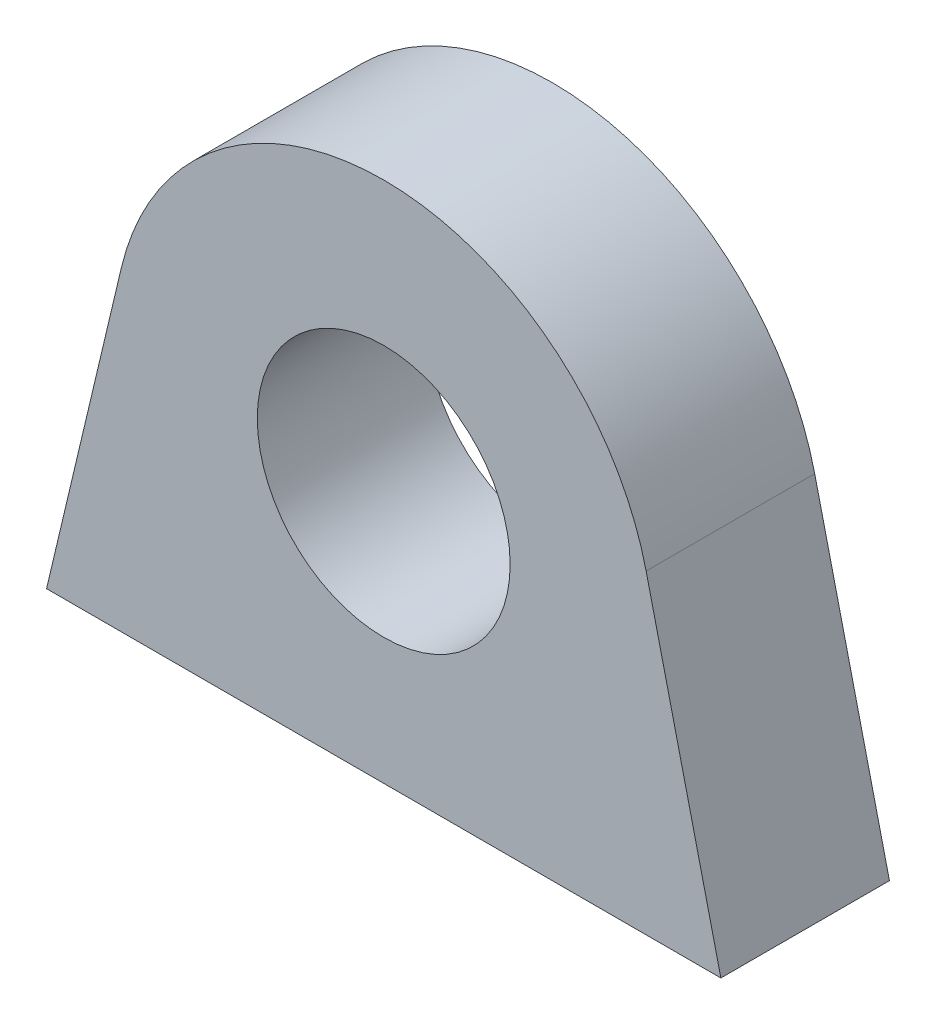
from build123d import *

# Parameters (mm, degrees)
SKETCH1_R           = 7.5
BOSS_EXTRUDE1_DEPTH = 10


with BuildPart() as part:
    # Sketch1 → Boss-Extrude1 (new body)
    with BuildSketch(Plane.XY):
        with BuildLine():
            Line((-20, 0), (20, 0))
            Line((20, 0), (15.56662128, 18.692083252))
            ThreePointArc((15.56662128, 18.692083252), (0, 30.998474203), (-15.56662128, 18.692083252))
            Line((-15.56662128, 18.692083252), (-20, 0))
        make_face()
        with Locations((0, 15)):
            Circle(SKETCH1_R, mode=Mode.SUBTRACT)
    extrude(amount=BOSS_EXTRUDE1_DEPTH)


solid = part.part
